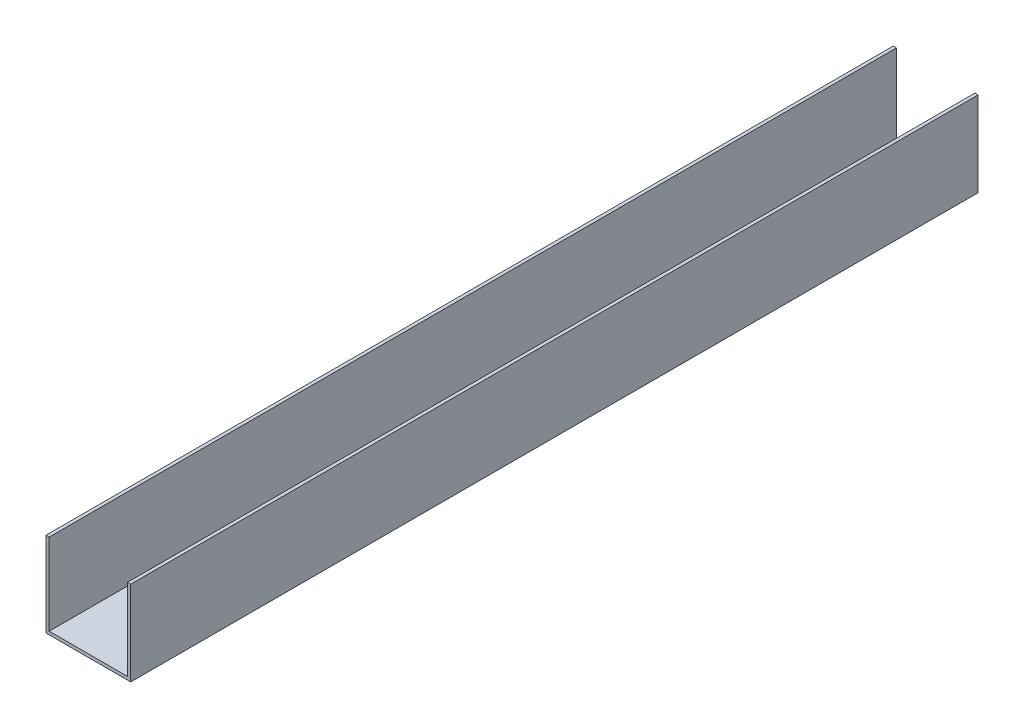
from build123d import *

# Parameters (mm, degrees)
CROQUIS1_W              = 400
CROQUIS1_H              = 40
SALIENTE_EXTRUIR1_DEPTH = 40
CROQUIS2_W              = 37
CROQUIS2_H              = 38.5
CORTAR_EXTRUIR1_DEPTH   = 401
CORTAR_EXTRUIR2_DEPTH   = 2.5
CORTAR_EXTRUIR3_DEPTH   = 2.5
CORTAR_EXTRUIR4_DEPTH   = 2.5
CORTAR_EXTRUIR5_DEPTH   = 2.5
CORTAR_EXTRUIR6_DEPTH   = 2.5
CORTAR_EXTRUIR7_DEPTH   = 2.5
CORTAR_EXTRUIR8_DEPTH   = 41


with BuildPart() as part:
    # Croquis1 → Saliente-Extruir1 (new body)
    with BuildSketch(Plane(origin=(20, 0, 0), x_dir=(0, 0, -1), z_dir=(1, 0, 0))):
        with Locations((-200, 18.5)):
            Rectangle(CROQUIS1_W, CROQUIS1_H)
    extrude(amount=-SALIENTE_EXTRUIR1_DEPTH)

    # Croquis2 → Cortar-Extruir1 (cut, through all)
    with BuildSketch(Plane.XY.offset(400)):
        with Locations((0, 19.25)):
            Rectangle(CROQUIS2_W, CROQUIS2_H)
    extrude(amount=-CORTAR_EXTRUIR1_DEPTH, mode=Mode.SUBTRACT)

    # Croquis3 → Cortar-Extruir2 (cut, through all)
    with BuildSketch(Plane(origin=(0, 0, 0), x_dir=(-1, 0, 0), z_dir=(0, 1, 0))):
        with BuildLine():
            Line((-3.25, 351.5), (-3.25, 338.5))
            ThreePointArc((-3.25, 338.5), (0, 335.25), (3.25, 338.5))
            Line((3.25, 338.5), (3.25, 351.5))
            ThreePointArc((3.25, 351.5), (0, 354.75), (-3.25, 351.5))
        make_face()
    extrude(amount=-CORTAR_EXTRUIR2_DEPTH, mode=Mode.SUBTRACT)

    # Croquis4 → Cortar-Extruir3 (cut, through all)
    with BuildSketch(Plane(origin=(0, 0, 0), x_dir=(-1, 0, 0), z_dir=(0, 1, 0))):
        with BuildLine():
            Line((-3.25, 301.5), (-3.25, 288.5))
            ThreePointArc((-3.25, 288.5), (0, 285.25), (3.25, 288.5))
            Line((3.25, 288.5), (3.25, 301.5))
            ThreePointArc((3.25, 301.5), (0, 304.75), (-3.25, 301.5))
        make_face()
    extrude(amount=-CORTAR_EXTRUIR3_DEPTH, mode=Mode.SUBTRACT)

    # Croquis5 → Cortar-Extruir4 (cut, through all)
    with BuildSketch(Plane(origin=(0, 0, 0), x_dir=(-1, 0, 0), z_dir=(0, 1, 0))):
        with BuildLine():
            Line((-3.25, 251.5), (-3.25, 238.5))
            ThreePointArc((-3.25, 238.5), (0, 235.25), (3.25, 238.5))
            Line((3.25, 238.5), (3.25, 251.5))
            ThreePointArc((3.25, 251.5), (0, 254.75), (-3.25, 251.5))
        make_face()
    extrude(amount=-CORTAR_EXTRUIR4_DEPTH, mode=Mode.SUBTRACT)

    # Croquis6 → Cortar-Extruir5 (cut, through all)
    with BuildSketch(Plane(origin=(0, 0, 0), x_dir=(-1, 0, 0), z_dir=(0, 1, 0))):
        with BuildLine():
            Line((-3.25, 201.5), (-3.25, 188.5))
            ThreePointArc((-3.25, 188.5), (0, 185.25), (3.25, 188.5))
            Line((3.25, 188.5), (3.25, 201.5))
            ThreePointArc((3.25, 201.5), (0, 204.75), (-3.25, 201.5))
        make_face()
    extrude(amount=-CORTAR_EXTRUIR5_DEPTH, mode=Mode.SUBTRACT)

    # Croquis7 → Cortar-Extruir6 (cut, through all)
    with BuildSketch(Plane(origin=(0, 0, 0), x_dir=(-1, 0, 0), z_dir=(0, 1, 0))):
        with BuildLine():
            Line((-3.25, 151.5), (-3.25, 138.5))
            ThreePointArc((-3.25, 138.5), (0, 135.25), (3.25, 138.5))
            Line((3.25, 138.5), (3.25, 151.5))
            ThreePointArc((3.25, 151.5), (0, 154.75), (-3.25, 151.5))
        make_face()
    extrude(amount=-CORTAR_EXTRUIR6_DEPTH, mode=Mode.SUBTRACT)

    # Croquis8 → Cortar-Extruir7 (cut, through all)
    with BuildSketch(Plane(origin=(0, 0, 0), x_dir=(-1, 0, 0), z_dir=(0, 1, 0))):
        with BuildLine():
            Line((-3.25, 101.5), (-3.25, 88.5))
            ThreePointArc((-3.25, 88.5), (0, 85.25), (3.25, 88.5))
            Line((3.25, 88.5), (3.25, 101.5))
            ThreePointArc((3.25, 101.5), (0, 104.75), (-3.25, 101.5))
        make_face()
    extrude(amount=-CORTAR_EXTRUIR7_DEPTH, mode=Mode.SUBTRACT)

    # Croquis9 → Cortar-Extruir8 (cut, through all)
    with BuildSketch(Plane.XZ.offset(1.5)):
        with BuildLine():
            Line((-3.25, 51.5), (-3.25, 38.5))
            ThreePointArc((-3.25, 38.5), (0, 35.25), (3.25, 38.5))
            Line((3.25, 38.5), (3.25, 51.5))
            ThreePointArc((3.25, 51.5), (0, 54.75), (-3.25, 51.5))
        make_face()
    extrude(amount=-CORTAR_EXTRUIR8_DEPTH, mode=Mode.SUBTRACT)


solid = part.part
